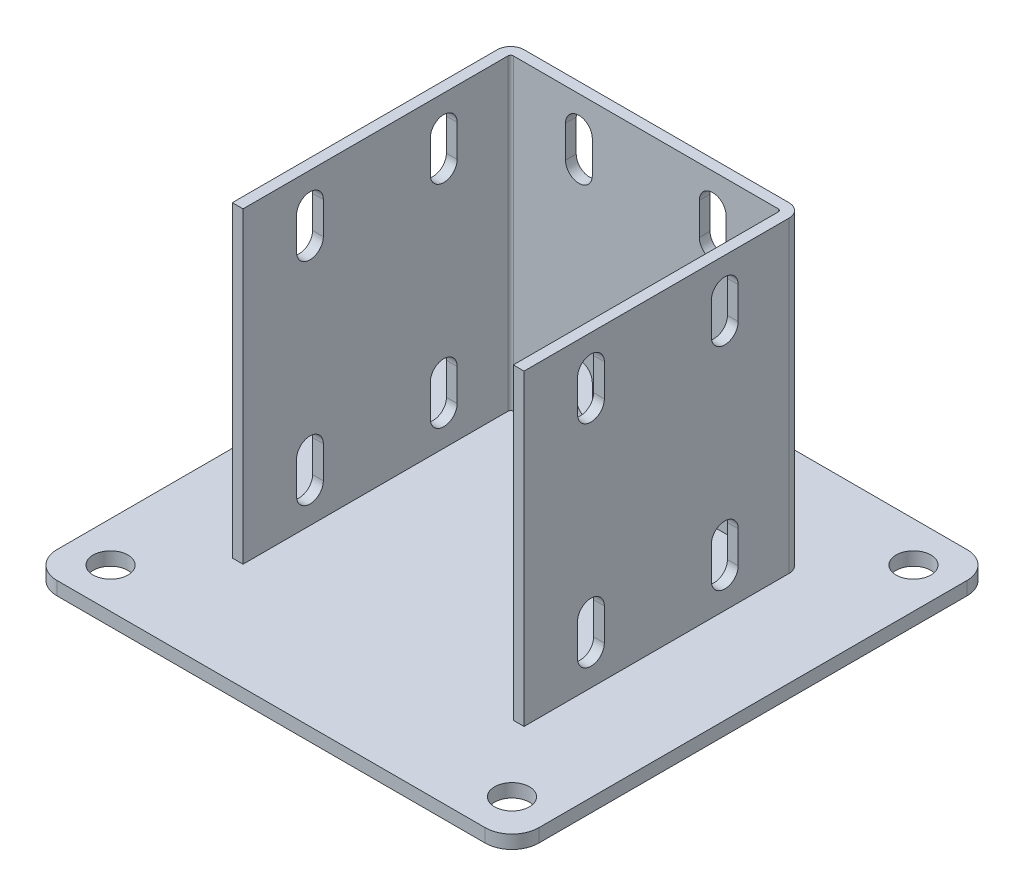
from build123d import *

# Parameters (mm, degrees)
SKETCH_2_W          = 180
SKETCH_2_H          = 180
EXTRUDE_1_DEPTH     = 5
EXTRUDE_1_2_DEPTH   = 115
EXTRUDE_2_DEPTH     = 2
CUT_EXTRUDE_1_DEPTH = 145.5
SKETCH_6_R          = 6.5
CUT_EXTRUDE_2_DEPTH = 6
FILLET_1_R          = 10
CUT_EXTRUDE_3_REACH = 146


with BuildPart() as part:
    # Эскиз2 → Extrude 1 (new body)
    with BuildSketch(Plane(origin=(0, 0, 0), x_dir=(1, 0, 0), z_dir=(0, 1, 0))):
        Rectangle(SKETCH_2_W, SKETCH_2_H)
    extrude(amount=EXTRUDE_1_DEPTH)

    # Эскиз3 → Extrude 1 2 (add)
    with BuildSketch(Plane(origin=(0, 5, 0), x_dir=(1, 0, 0), z_dir=(0, 1, 0))):
        with BuildLine():
            Line((-50.5, -50), (-50.5, 49))
            ThreePointArc((-50.5, 49), (-50.207106781, 49.707106781), (-49.5, 50))
            Line((-49.5, 50), (49.5, 50))
            ThreePointArc((49.5, 50), (50.207106781, 49.707106781), (50.5, 49))
            Line((50.5, 49), (50.5, -50))
            Line((50.5, -50), (54.5, -50))
            Line((54.5, -50), (54.5, 49))
            ThreePointArc((54.5, 49), (53.035533906, 52.535533906), (49.5, 54))
            Line((49.5, 54), (-49.5, 54))
            ThreePointArc((-49.5, 54), (-53.035533906, 52.535533906), (-54.5, 49))
            Line((-54.5, 49), (-54.5, -50))
            Line((-54.5, -50), (-50.5, -50))
        make_face()
    extrude(amount=EXTRUDE_1_2_DEPTH)

    # Эскиз4 → Бобышка-Вытянуть2 (add, symmetric)
    with BuildSketch(Plane(origin=(0, 0, 0), x_dir=(0, 0, -1), z_dir=(1, 0, 0))):
        Polygon((54, 58.693575035), (85, 5), (54, 5), align=None)
    extrude(amount=EXTRUDE_2_DEPTH, both=True)

    # Эскиз5 → Вырез-Вытянуть1 (cut, through all)
    with BuildSketch(Plane(origin=(54.5, 0, 0), x_dir=(0, 0, -1), z_dir=(1, 0, 0))):
        with BuildLine():
            Line((-20, 108), (-20, 96))
            ThreePointArc((-20, 96), (-25, 91), (-30, 96))
            Line((-30, 96), (-30, 108))
            ThreePointArc((-30, 108), (-25, 113), (-20, 108))
        make_face()
        with BuildLine():
            Line((-20, 29), (-20, 17))
            ThreePointArc((-20, 17), (-25, 12), (-30, 17))
            Line((-30, 17), (-30, 29))
            ThreePointArc((-30, 29), (-25, 34), (-20, 29))
        make_face()
        with BuildLine():
            Line((20, 108), (20, 96))
            ThreePointArc((20, 96), (25, 91), (30, 96))
            Line((30, 96), (30, 108))
            ThreePointArc((30, 108), (25, 113), (20, 108))
        make_face()
        with BuildLine():
            Line((20, 29), (20, 17))
            ThreePointArc((20, 17), (25, 12), (30, 17))
            Line((30, 17), (30, 29))
            ThreePointArc((30, 29), (25, 34), (20, 29))
        make_face()
    extrude(amount=-CUT_EXTRUDE_1_DEPTH, mode=Mode.SUBTRACT)

    # Эскиз6 → Вырез-Вытянуть2 (cut, through all)
    with BuildSketch(Plane(origin=(0, 5, 0), x_dir=(1, 0, 0), z_dir=(0, 1, 0))):
        with Locations(Location((-75, 75, 0), (0, 0, 270))):  # turned: the seam where the file's is
            Circle(SKETCH_6_R)
        with Locations(Location((-75, -75, 0), (0, 0, 270))):  # turned: the seam where the file's is
            Circle(SKETCH_6_R)
        with Locations(Location((75, 75, 0), (0, 0, 270))):  # turned: the seam where the file's is
            Circle(SKETCH_6_R)
        with Locations(Location((75, -75, 0), (0, 0, 270))):  # turned: the seam where the file's is
            Circle(SKETCH_6_R)
    extrude(amount=-CUT_EXTRUDE_2_DEPTH, mode=Mode.SUBTRACT)

    # Скругление1
    fillet_1_edges = [part.edges().sort_by_distance(p)[0] for p in [
        (90, 2.5, 90),
        (-90, 2.5, 90),
        (-90, 2.5, -90),
        (90, 2.5, -90),
    ]]
    fillet(fillet_1_edges, radius=FILLET_1_R)

    # Эскиз8 → Вырез-Вытянуть3 (cut, up to next)
    with BuildSketch(Plane(origin=(0, 0, -54), x_dir=(-1, 0, 0), z_dir=(0, 0, -1)), mode=Mode.PRIVATE) as cut_extrude_3_sk1:
        with BuildLine():
            Line((-20, 108), (-20, 96))
            ThreePointArc((-20, 96), (-25, 91), (-30, 96))
            Line((-30, 96), (-30, 108))
            ThreePointArc((-30, 108), (-25, 113), (-20, 108))
        make_face()
    cut_extrude_3_tool1 = extrude(cut_extrude_3_sk1.sketch, amount=-CUT_EXTRUDE_3_REACH, mode=Mode.PRIVATE) & part.part
    add(cut_extrude_3_tool1.solids().sort_by_distance((25, 102, -54))[0], mode=Mode.SUBTRACT)
    # Эскиз8 → Вырез-Вытянуть3 (cut, up to next)
    with BuildSketch(Plane(origin=(0, 0, -54), x_dir=(-1, 0, 0), z_dir=(0, 0, -1)), mode=Mode.PRIVATE) as cut_extrude_3_sk2:
        with BuildLine():
            Line((-20, 29), (-20, 17))
            ThreePointArc((-20, 17), (-25, 12), (-30, 17))
            Line((-30, 17), (-30, 29))
            ThreePointArc((-30, 29), (-25, 34), (-20, 29))
        make_face()
    cut_extrude_3_tool2 = extrude(cut_extrude_3_sk2.sketch, amount=-CUT_EXTRUDE_3_REACH, mode=Mode.PRIVATE) & part.part
    add(cut_extrude_3_tool2.solids().sort_by_distance((25, 23, -54))[0], mode=Mode.SUBTRACT)
    # Эскиз8 → Вырез-Вытянуть3 (cut, up to next)
    with BuildSketch(Plane(origin=(0, 0, -54), x_dir=(-1, 0, 0), z_dir=(0, 0, -1)), mode=Mode.PRIVATE) as cut_extrude_3_sk3:
        with BuildLine():
            Line((20, 108), (20, 96))
            ThreePointArc((20, 96), (25, 91), (30, 96))
            Line((30, 96), (30, 108))
            ThreePointArc((30, 108), (25, 113), (20, 108))
        make_face()
    cut_extrude_3_tool3 = extrude(cut_extrude_3_sk3.sketch, amount=-CUT_EXTRUDE_3_REACH, mode=Mode.PRIVATE) & part.part
    add(cut_extrude_3_tool3.solids().sort_by_distance((-25, 102, -54))[0], mode=Mode.SUBTRACT)
    # Эскиз8 → Вырез-Вытянуть3 (cut, up to next)
    with BuildSketch(Plane(origin=(0, 0, -54), x_dir=(-1, 0, 0), z_dir=(0, 0, -1)), mode=Mode.PRIVATE) as cut_extrude_3_sk4:
        with BuildLine():
            Line((20, 29), (20, 17))
            ThreePointArc((20, 17), (25, 12), (30, 17))
            Line((30, 17), (30, 29))
            ThreePointArc((30, 29), (25, 34), (20, 29))
        make_face()
    cut_extrude_3_tool4 = extrude(cut_extrude_3_sk4.sketch, amount=-CUT_EXTRUDE_3_REACH, mode=Mode.PRIVATE) & part.part
    add(cut_extrude_3_tool4.solids().sort_by_distance((-25, 23, -54))[0], mode=Mode.SUBTRACT)


solid = part.part
